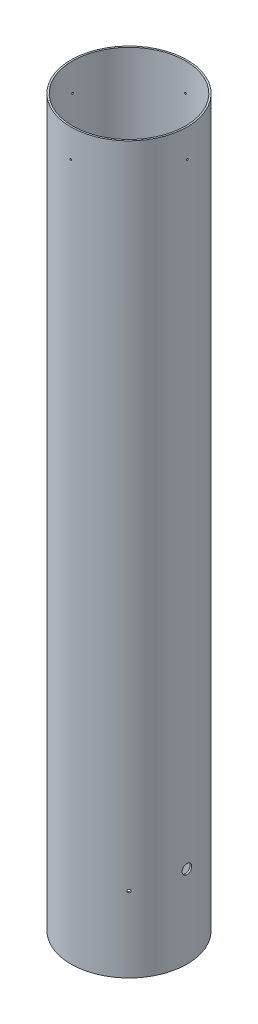
from build123d import *

# Parameters (mm, degrees)
SKETCH1_R           = 78.359
SKETCH1_R_2         = 76.1746
BOSS_EXTRUDE1_DEPTH = 977.9
SKETCH2_R           = 1.0922
CUT_EXTRUDE1_DEPTH  = 985.158867136
CIRPATTERN1_COUNT   = 4
CIRPATTERN2_COUNT   = 4


with BuildPart() as part:
    # Sketch1 → Boss-Extrude1 (new body)
    with BuildSketch(Plane(origin=(0, 0, 0), x_dir=(1, 0, 0), z_dir=(0, 1, 0))):
        Circle(SKETCH1_R)
        Circle(SKETCH1_R_2, mode=Mode.SUBTRACT)
    extrude(amount=BOSS_EXTRUDE1_DEPTH)

    # Sketch2 → Cut-Extrude1 (cut, through all)
    with BuildSketch(Plane(origin=(0, 0, 0), x_dir=(0, 0, -1), z_dir=(1, 0, 0))):
        with Locations((0, 939.8)):
            Circle(SKETCH2_R)
    cut_extrude1 = extrude(amount=-CUT_EXTRUDE1_DEPTH, mode=Mode.SUBTRACT)

    # CirPattern1: Cut-Extrude1 ×4 about axis
    cirpattern1_axis = Axis((0, 977.9, 0), (0, 1, 0))
    for i in range(1, CIRPATTERN1_COUNT):
        add(cut_extrude1.rotate(cirpattern1_axis, i * 360 / CIRPATTERN1_COUNT), mode=Mode.SUBTRACT)

    # Sketch4 → 1_2 Clearance Hole1 (revolve, cut)
    with BuildSketch(Plane.ZX.offset(111.125)):
        Polygon((0, 0), (0, 92.834507437), (6.54812, 88.9), (6.54812, 0), align=None)
    revolve(axis=Axis((-6.35, 111.125, 0), (1, 0, 0)), mode=Mode.SUBTRACT)

    # Sketch6 → Ø4.0 (4) Diameter Hole1 (revolve, cut)
    with BuildSketch(Plane(origin=(0, 101.6, 0), x_dir=(0.7071067811865488, 0, -0.7071067811865464), z_dir=(0, 1, 0))):
        Polygon((0, 0), (0, 90.101721238), (2, 88.9), (2, 0), align=None)
    f_4_0_4_diameter_hole1 = revolve(axis=Axis((4.490128061, 101.6, 4.490128061), (-0.7071067811865464, 0, -0.7071067811865487)), mode=Mode.SUBTRACT)

    # CirPattern2: Ø4.0 (4) Diameter Hole1 ×4 about axis
    cirpattern2_axis = Axis((0, 0, 0), (0, 1, 0))
    for i in range(1, CIRPATTERN2_COUNT):
        add(f_4_0_4_diameter_hole1.rotate(cirpattern2_axis, i * 360 / CIRPATTERN2_COUNT), mode=Mode.SUBTRACT)


solid = part.part
